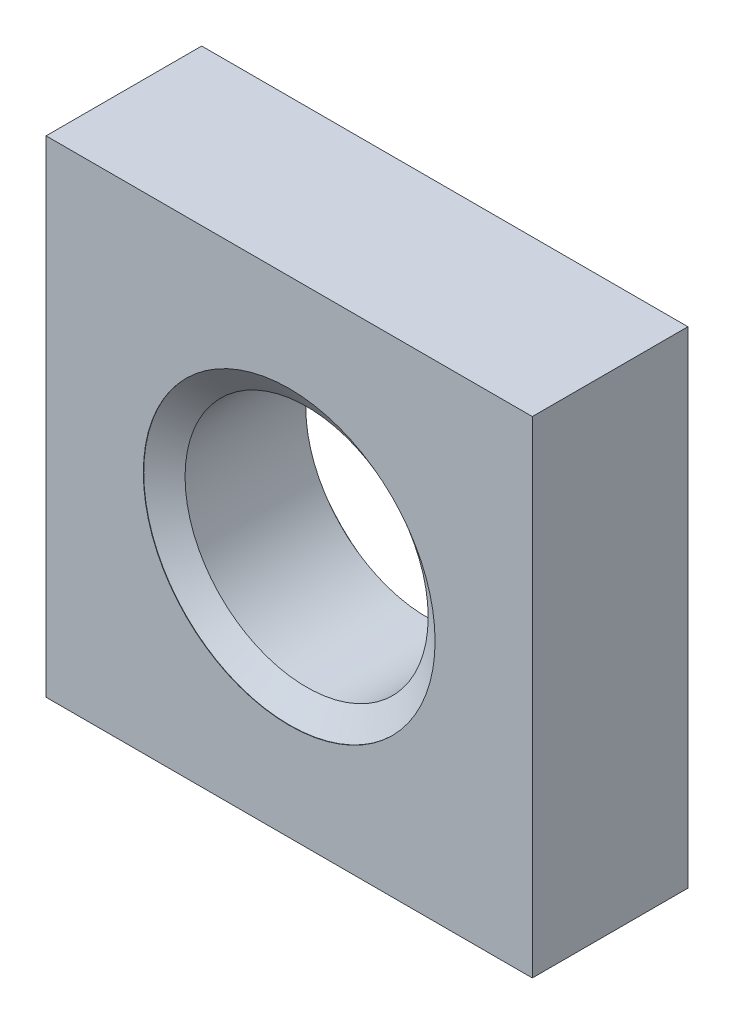
from build123d import *

# Parameters (mm, degrees)
BASENUT_START = -3.2
BASENUTSKE_W  = 10
BASENUTSKE_H  = 10
BASENUTSKE_R  = 2.5
BASENUT_DEPTH = 3.2


with BuildPart() as part:
    # BaseNutSke → BaseNut (new body)
    with BuildSketch(Plane.XY.offset(BASENUT_START)):
        Rectangle(BASENUTSKE_W, BASENUTSKE_H)
        Circle(BASENUTSKE_R, mode=Mode.SUBTRACT)
    extrude(amount=BASENUT_DEPTH)

    # EndChamferSketch → EndChamfer (revolve, cut)
    with BuildSketch(Plane(origin=(0, 0, 0), x_dir=(0, 0, -1), z_dir=(1, 0, 0))):
        Polygon((3.191, 3), (2.805885854, 2.45), (3.201, 2.45), (3.201, 3), align=None)
        Polygon((-0.002, 3), (0.008, 3), (0.393114146, 2.45), (-0.002, 2.45), align=None)
    revolve(axis=Axis((0, 0, -25.037505729), (0, 0, -1)), mode=Mode.SUBTRACT)


solid = part.part
